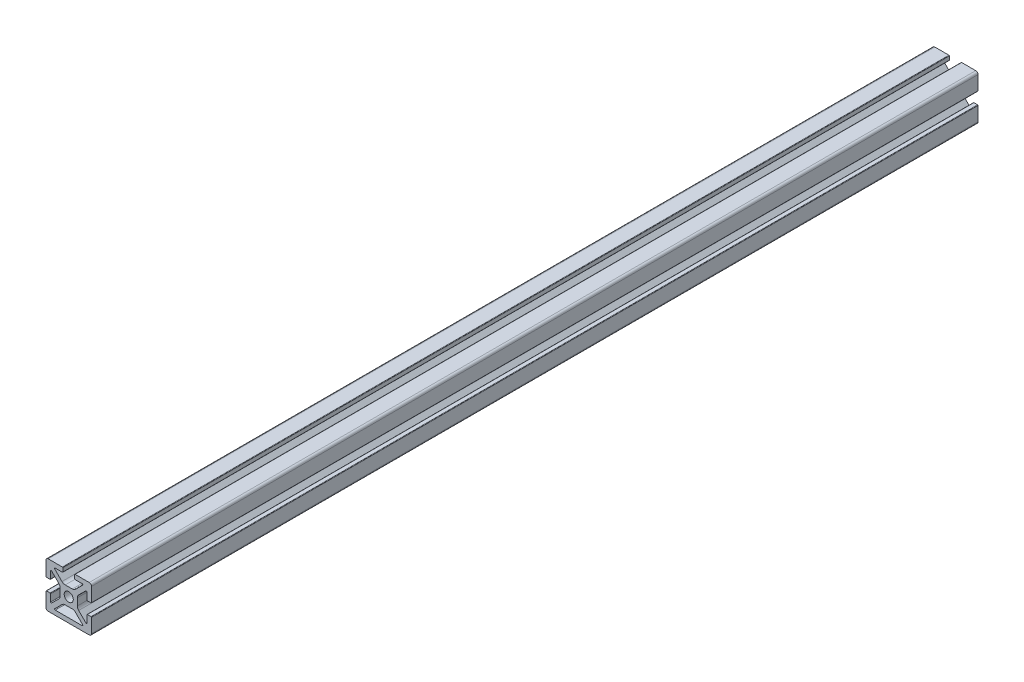
from build123d import *

# Parameters (mm, degrees)
BOSS_EXTRUDE1_DEPTH = 247.65
FILLET2_R           = 0.254
FILLET1_R           = 1.27
SKETCH5_W           = 7.112
SKETCH5_H           = 2.54
BOSS_EXTRUDE2_DEPTH = 495.3


with BuildPart() as part:
    # Sketch3 → Boss-Extrude1 (new body, symmetric)
    with BuildSketch(Plane.XY):
        with BuildLine():
            Line((-12.7, 12.7), (-1.796051224, 1.796051224))
            ThreePointArc((-1.796051224, 1.796051224), (-0.972015918, 2.346654013), (0, 2.54))
            Line((0, 2.54), (0, 4.826))
            Line((0, 4.826), (-1.977846327, 4.826))
            ThreePointArc((-1.977846327, 4.826), (-2.949862246, 5.019345987), (-3.773897552, 5.569948776))
            Line((-3.773897552, 5.569948776), (-7.772528286, 9.56857951))
            ThreePointArc((-7.772528286, 9.56857951), (-7.847628361, 9.946133082), (-7.527553898, 10.16))
            Line((-7.527553898, 10.16), (-3.302, 10.16))
            Line((-3.302, 10.16), (-3.302, 12.7))
            Line((-3.302, 12.7), (-12.7, 12.7))
        make_face()
    extrude(amount=BOSS_EXTRUDE1_DEPTH, both=True)

    # Fillet2
    fillet2_edges = [part.edges().sort_by_distance(p)[0] for p in [
        (-3.302, 12.7, 0),
        (-3.302, 10.16, 0),
    ]]
    fillet(fillet2_edges, radius=FILLET2_R)

    # Mirror1: part across plane


with BuildPart() as part_1:
    add(part.part)
    add(part.part.mirror(Plane(origin=(0, 0, 247.65), x_dir=(0, 0, 1), z_dir=(0.707106781, 0.707106781, 0))))

    # Fillet1
    fillet1_edges = [part_1.edges().sort_by_distance(p)[0] for p in [
        (-12.7, 12.7, 0),
    ]]
    fillet(fillet1_edges, radius=FILLET1_R)

    # Mirror2: part across plane


with BuildPart() as part_2:
    add(part_1.part)
    add(part_1.part.mirror(Plane(origin=(0, 0, 247.65), x_dir=(0, 0, 1), z_dir=(0, 1, 0))))

    # Mirror5: part across plane


with BuildPart() as part_3:
    add(part_2.part)
    add(part_2.part.mirror(Plane(origin=(0, 0, 247.65), x_dir=(0, 0, 1), z_dir=(-1, 0, 0))))

    # Sketch5 → Boss-Extrude2 (add, through all)
    with BuildSketch(Plane.XY.offset(247.65)):
        with Locations((0, -11.43)):
            Rectangle(SKETCH5_W, SKETCH5_H)
    extrude(amount=-BOSS_EXTRUDE2_DEPTH)


solid = part_3.part
